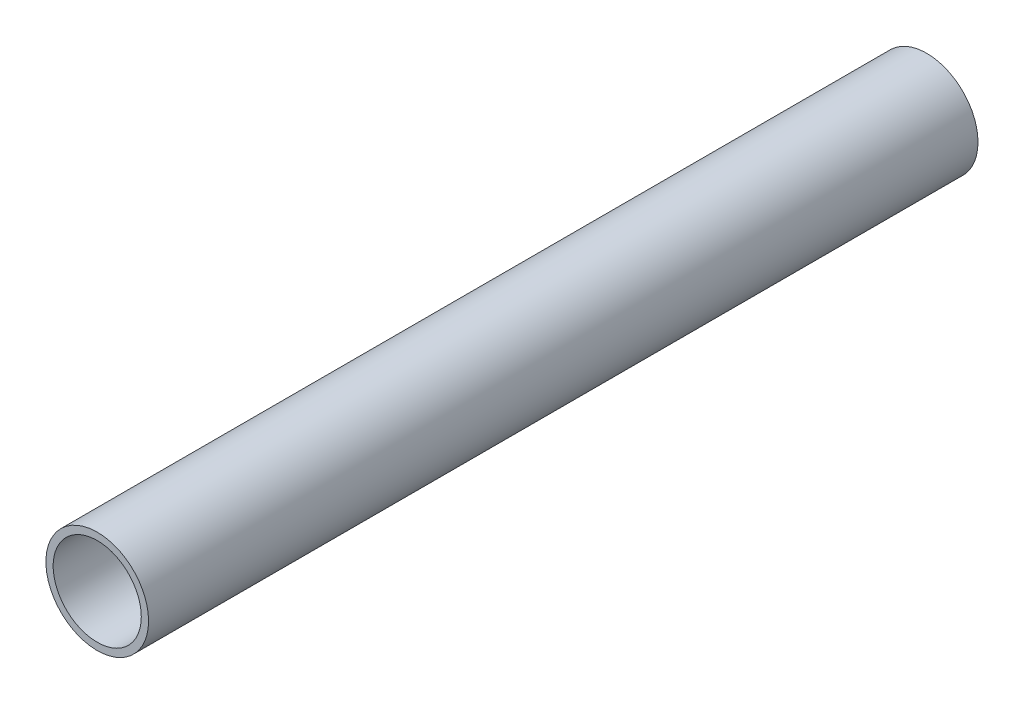
from build123d import *

# Parameters (mm, degrees)
SKETCH1_R           = 12.573
SKETCH1_R_2         = 10.795
BOSS_EXTRUDE1_DEPTH = 203.2


with BuildPart() as part:
    # Sketch1 → Boss-Extrude1 (new body)
    with BuildSketch(Plane.XY):
        Circle(SKETCH1_R)
        Circle(SKETCH1_R_2, mode=Mode.SUBTRACT)
    extrude(amount=BOSS_EXTRUDE1_DEPTH)


solid = part.part
